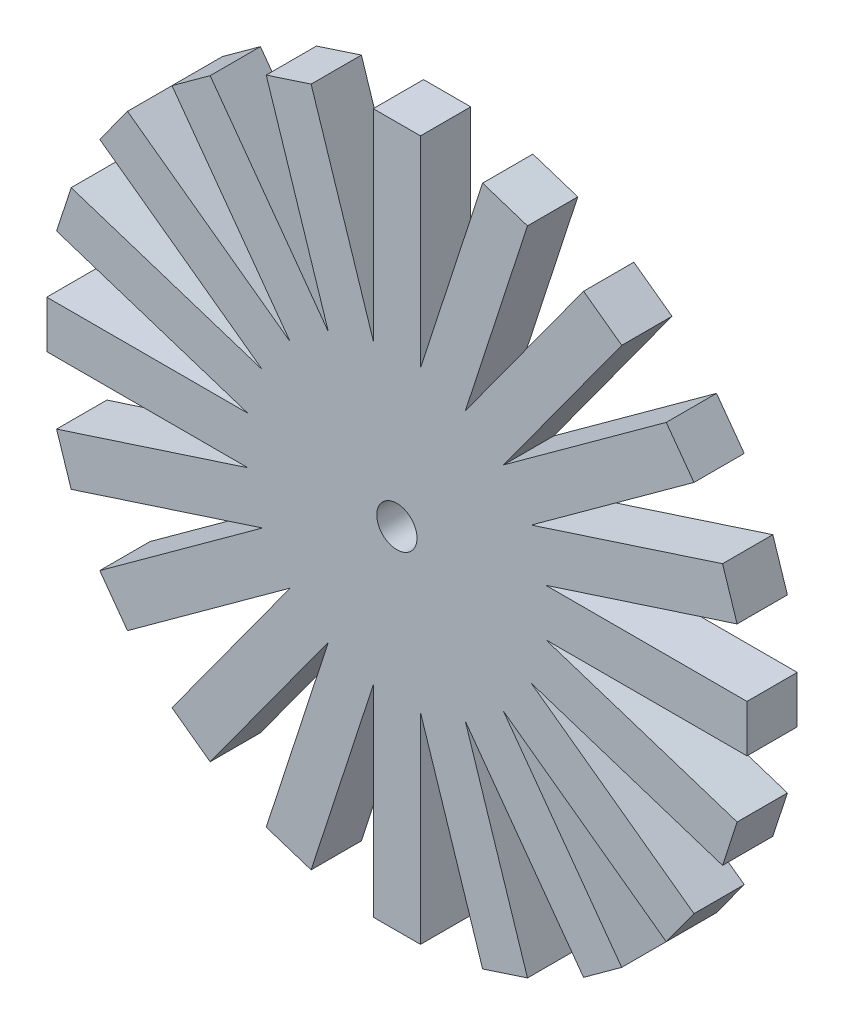
from build123d import *

# Parameters (mm, degrees)
ESQUISSE1_R        = 2
BOSS_EXTRU_1_DEPTH = 5


with BuildPart() as part:
    # Esquisse1 → Boss.-Extru.1 (new body)
    with BuildSketch(Plane.XY):
        Polygon((-14.815325109, -2.346516976), (-34.815325109, -2.346516976), (-34.815325109, 2.346516976), (-14.815325109, 2.346516976), (-33.836455435, 8.526856863), (-32.386228189, 12.990197384), (-13.365097863, 6.809857496), (-29.54543775, 18.565562542), (-26.786941605, 22.362306764), (-10.606601718, 10.606601718), (-22.362306764, 26.786941605), (-18.565562542, 29.54543775), (-6.809857496, 13.365097863), (-12.990197384, 32.386228189), (-8.526856863, 33.836455435), (-2.346516976, 14.815325109), (-2.346516976, 34.815325109), (2.346516976, 34.815325109), (2.346516976, 14.815325109), (8.526856863, 33.836455435), (12.990197384, 32.386228189), (6.809857496, 13.365097863), (18.565562542, 29.54543775), (22.362306764, 26.786941605), (10.606601718, 10.606601718), (26.786941605, 22.362306764), (29.54543775, 18.565562542), (13.365097863, 6.809857496), (32.386228189, 12.990197384), (33.836455435, 8.526856863), (14.815325109, 2.346516976), (34.815325109, 2.346516976), (34.815325109, -2.346516976), (14.815325109, -2.346516976), (33.836455435, -8.526856863), (32.386228189, -12.990197384), (13.365097863, -6.809857496), (29.54543775, -18.565562542), (26.786941605, -22.362306764), (10.606601718, -10.606601718), (22.362306764, -26.786941605), (18.565562542, -29.54543775), (6.809857496, -13.365097863), (12.990197384, -32.386228189), (8.526856863, -33.836455435), (2.346516976, -14.815325109), (2.346516976, -34.815325109), (-2.346516976, -34.815325109), (-2.346516976, -14.815325109), (-8.526856863, -33.836455435), (-12.990197384, -32.386228189), (-6.809857496, -13.365097863), (-18.565562542, -29.54543775), (-22.362306764, -26.786941605), (-10.606601718, -10.606601718), (-26.786941605, -22.362306764), (-29.54543775, -18.565562542), (-13.365097863, -6.809857496), (-32.386228189, -12.990197384), (-33.836455435, -8.526856863), align=None)
        Circle(ESQUISSE1_R, mode=Mode.SUBTRACT)
    extrude(amount=BOSS_EXTRU_1_DEPTH)


solid = part.part
